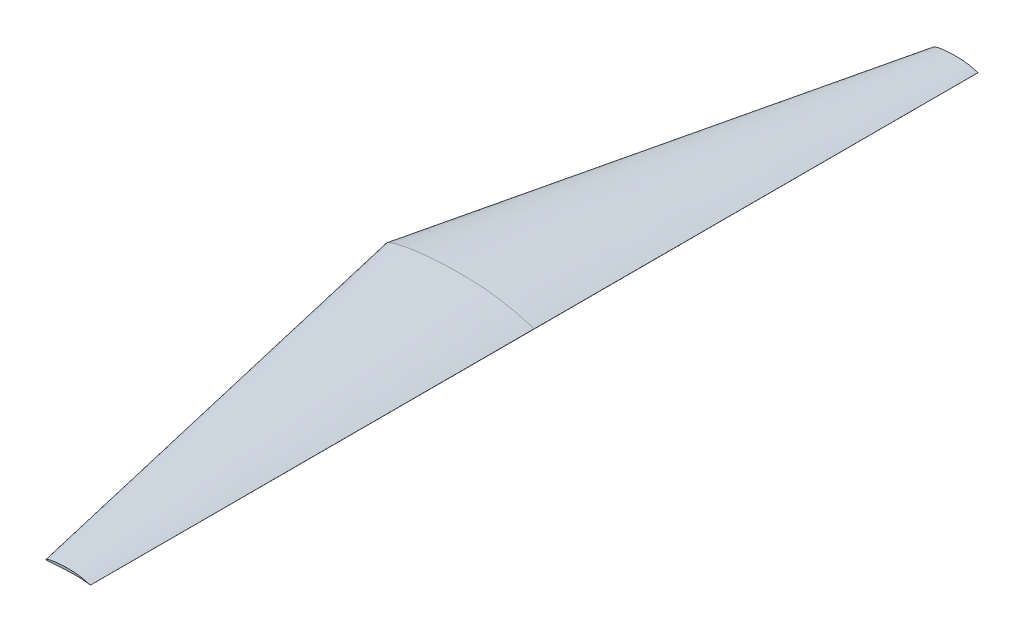
from build123d import *


with BuildPart() as part:
    # Sketch4 → Loft2 section 0
    with BuildSketch(Plane.XY):
        with BuildLine():
            Line((254, 0.16002), (254, -0.16002))
            add(Edge.make_bspline(
                [(254, 0.16002), (253.390629454, 0.354175237), (251.690668177, 0.895810186), (248.604296931, 1.85288401), (244.52112065, 3.078669041), (237.836543091, 5.001150781), (226.150380006, 8.105969834), (213.696555504, 10.897249381), (200.19271656, 13.439194797), (190.694763803, 14.954214101), (181.020644525, 16.211857643), (173.636826015, 17.023703791), (166.199070493, 17.689254207), (158.731422647, 18.207728416), (151.255016436, 18.558178008), (143.793435306, 18.808525374), (136.365371988, 18.982864571), (126.580287151, 19.10330287), (116.897768939, 19.062538903), (105.049830105, 18.80743863), (95.806609799, 18.448533981), (86.75342576, 17.932151324), (80.193784455, 17.477656056), (73.8084741, 16.955652117), (67.610444284, 16.370082301), (61.612207157, 15.725608708), (55.825958129, 15.026947866), (50.26350266, 14.279537471), (44.936361976, 13.488925842), (39.85571923, 12.661108902), (35.03251259, 11.802241155), (30.477367111, 10.918871422), (26.200693126, 10.017491703), (22.21264515, 9.104790925), (18.523095578, 8.187588491), (15.141745593, 7.272501124), (12.07799891, 6.366180193), (9.341001209, 5.475112821), (6.93958574, 4.605405592), (4.881967231, 3.763333086), (3.175781694, 2.953809462), (1.826208271, 2.183451538), (0.83591509, 1.449975898), (0.195044297, 0.755243682), (-0.080371712, 0.023167401), (0.172753263, -0.677671692), (0.849170255, -1.179205828), (1.842090873, -1.582429994), (3.193702875, -1.908807147), (4.898004058, -2.162494559), (6.954352036, -2.34405578), (9.354357986, -2.45479332), (12.090213212, -2.496659599), (15.152965113, -2.47199544), (18.533464993, -2.383498376), (22.222249739, -2.234359789), (26.209611272, -2.027891847), (30.485635842, -1.767925293), (35.040144284, -1.458327467), (39.862742707, -1.103564992), (44.942764219, -0.708051848), (50.269283211, -0.276652482), (55.831105217, 0.18559398), (61.616722221, 0.673443271), (67.614311842, 1.181498394), (73.811698837, 1.704276447), (80.19637044, 2.236010885), (86.755378935, 2.771217854), (95.809287784, 3.489259789), (107.457608855, 4.362783785), (119.305120019, 5.160909961), (128.987553621, 5.746406357), (136.363605474, 6.156349197), (143.791379186, 6.528814259), (151.251536552, 6.867228061), (158.725078073, 7.143888445), (166.192393719, 7.286534308), (173.629649411, 7.312051473), (181.013152794, 7.216973143), (190.676776551, 6.937250087), (202.410619783, 6.31909946), (215.89428223, 5.195415931), (226.535561083, 4.003426038), (234.429284596, 2.961850752), (239.743242642, 2.196611542), (244.516892529, 1.457116015), (248.601370153, 0.784629743), (251.689075327, 0.252887242), (253.390531541, -0.051122491), (254, -0.16002)],
                knots=[0, 0, 0, 0, 0.003728993, 0.010402774, 0.018840568, 0.028585709, 0.050956865, 0.089334271, 0.10297657, 0.131071145, 0.145402462, 0.159853793, 0.174379924, 0.188939766, 0.203496108, 0.218017346, 0.232469302, 0.246817477, 0.275073667, 0.28892109, 0.315912882, 0.329003977, 0.341791348, 0.354250441, 0.366357575, 0.378089701, 0.389424235, 0.400339091, 0.410812773, 0.420824001, 0.430352033, 0.439376412, 0.447877061, 0.455834383, 0.463229144, 0.470042802, 0.476257372, 0.481856009, 0.486823221, 0.491145842, 0.494814445, 0.497826693, 0.500195359, 0.501969932, 0.50330007, 0.504508604, 0.506012742, 0.508062771, 0.510747122, 0.514093105, 0.518105083, 0.522777318, 0.528099107, 0.534056683, 0.540634481, 0.547815449, 0.555581622, 0.563914059, 0.572793129, 0.582198376, 0.592108707, 0.602502417, 0.613356987, 0.624649417, 0.636355909, 0.648451947, 0.660912408, 0.673711425, 0.68682217, 0.713868083, 0.741818751, 0.756056506, 0.770425669, 0.784891946, 0.799419294, 0.813967731, 0.828495783, 0.842964095, 0.857330143, 0.871547876, 0.89933031, 0.925831588, 0.950429236, 0.961757467, 0.972254714, 0.981731905, 0.989922338, 0.996390141, 1, 1, 1, 1], degree=3))
        make_face()
    # Sketch5 → Loft2 section 1
    with BuildSketch(Plane.XY.offset(762)):
        with BuildLine():
            Line((254, 0.048006), (254, -0.048006))
            add(Edge.make_bspline(
                [(254, 0.048006), (253.817188836, 0.106252571), (253.307200453, 0.268743056), (252.381289079, 0.555865203), (251.156336195, 0.923600712), (249.150962927, 1.500345234), (245.645114002, 2.43179095), (241.908966651, 3.269174814), (237.857814968, 4.031758439), (235.008429141, 4.48626423), (232.106193357, 4.863557293), (229.891047804, 5.107111137), (227.659721148, 5.306776262), (225.419426794, 5.462318525), (223.176504931, 5.567453402), (220.938030592, 5.642557612), (218.709611597, 5.694859371), (215.774086145, 5.730990861), (212.869330682, 5.718761671), (209.314949031, 5.642231589), (206.54198294, 5.534560194), (203.826027728, 5.379645397), (201.858135337, 5.243296817), (199.94254223, 5.086695635), (198.083133285, 4.91102469), (196.283662147, 4.717682612), (194.547787439, 4.50808436), (192.879050798, 4.283861241), (191.280908593, 4.046677753), (189.756715769, 3.798332671), (188.309753777, 3.540672346), (186.943210133, 3.275661427), (185.660207938, 3.005247511), (184.463793545, 2.731437277), (183.356928673, 2.456276547), (182.342523678, 2.181750337), (181.423399673, 1.909854058), (180.602300363, 1.642533846), (179.881875722, 1.381621678), (179.264590169, 1.128999926), (178.752734508, 0.886142839), (178.347862481, 0.655035461), (178.050774527, 0.434992769), (177.858513289, 0.226573105), (177.775888486, 0.00695022), (177.851825979, -0.203301508), (178.054751076, -0.353761748), (178.352627262, -0.474728998), (178.758110863, -0.572642144), (179.269401217, -0.648748368), (179.886305611, -0.703216734), (180.606307396, -0.736437996), (181.427063964, -0.74899788), (182.345889534, -0.741598632), (183.360039498, -0.715049513), (184.466674922, -0.670307937), (185.662883381, -0.608367554), (186.945690753, -0.530377588), (188.312043285, -0.43749824), (189.758822812, -0.331069498), (191.282829266, -0.212415554), (192.880784963, -0.082995745), (194.549331565, 0.055678194), (196.285016666, 0.202032981), (198.084293553, 0.354449518), (199.943509651, 0.511282934), (201.858911132, 0.670803266), (203.826613681, 0.831365356), (206.542786335, 1.046777937), (210.037282656, 1.308835135), (213.591536006, 1.548272988), (216.496266086, 1.723921907), (218.709081642, 1.846904759), (220.937413756, 1.958644278), (223.175460965, 2.060168418), (225.417523422, 2.143166533), (227.657718116, 2.185960293), (229.888894823, 2.193615442), (232.103945838, 2.165091943), (235.003032965, 2.081175026), (238.523185935, 1.895729838), (242.568284669, 1.558624779), (245.760668325, 1.201027811), (248.128785379, 0.888555226), (249.722972793, 0.658983463), (251.155067759, 0.437134805), (252.380411046, 0.235388923), (253.306722598, 0.075866173), (253.817159462, -0.015336747), (254, -0.048006)],
                knots=[0, 0, 0, 0, 0.003728993, 0.010402774, 0.018840568, 0.028585709, 0.050956865, 0.089334271, 0.10297657, 0.131071145, 0.145402462, 0.159853793, 0.174379924, 0.188939766, 0.203496108, 0.218017346, 0.232469302, 0.246817477, 0.275073667, 0.28892109, 0.315912882, 0.329003977, 0.341791348, 0.354250441, 0.366357575, 0.378089701, 0.389424235, 0.400339091, 0.410812773, 0.420824001, 0.430352033, 0.439376412, 0.447877061, 0.455834383, 0.463229144, 0.470042802, 0.476257372, 0.481856009, 0.486823221, 0.491145842, 0.494814445, 0.497826693, 0.500195359, 0.501969932, 0.50330007, 0.504508604, 0.506012742, 0.508062771, 0.510747122, 0.514093105, 0.518105083, 0.522777318, 0.528099107, 0.534056683, 0.540634481, 0.547815449, 0.555581622, 0.563914059, 0.572793129, 0.582198376, 0.592108707, 0.602502417, 0.613356987, 0.624649417, 0.636355909, 0.648451947, 0.660912408, 0.673711425, 0.68682217, 0.713868083, 0.741818751, 0.756056506, 0.770425669, 0.784891946, 0.799419294, 0.813967731, 0.828495783, 0.842964095, 0.857330143, 0.871547876, 0.89933031, 0.925831588, 0.950429236, 0.961757467, 0.972254714, 0.981731905, 0.989922338, 0.996390141, 1, 1, 1, 1], degree=3))
        make_face()
    loft2 = loft()

    # Mirror1: Loft2 across plane
    add(loft2.mirror(Plane(origin=(0.857099192, 1.42359733, 0), x_dir=(1, 0, 0), z_dir=(0, 0, -1))))


solid = part.part
